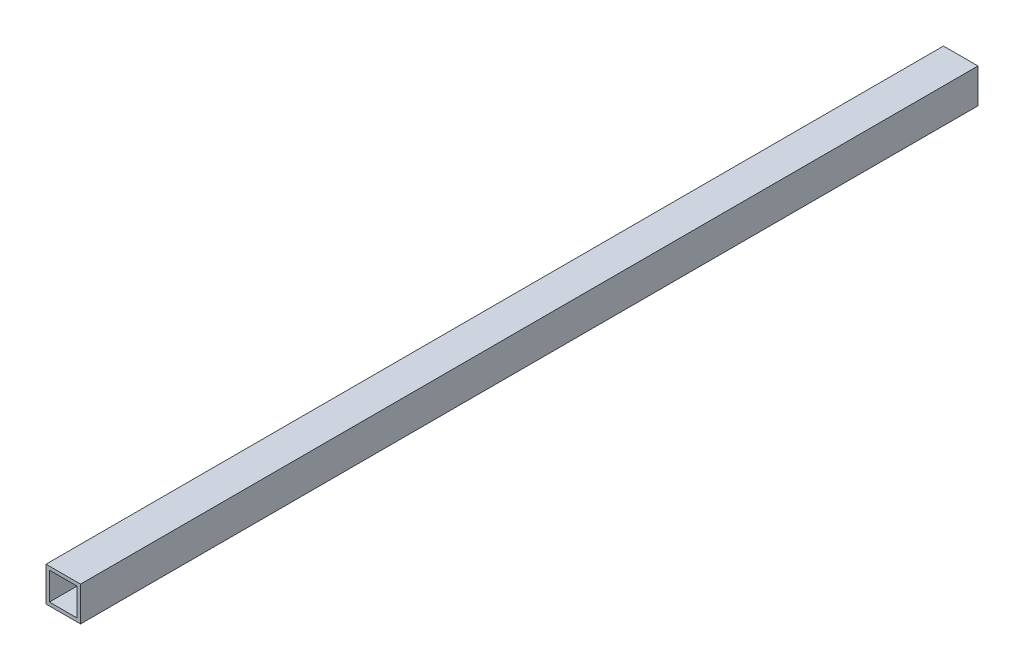
from build123d import *

# Parameters (mm, degrees)
SKETCH1_W   = 40
SKETCH1_H   = 40
SKETCH1_W_2 = 32
SKETCH1_H_2 = 32


with BuildPart() as part:
    # Sweep1: sweep along a curve in space
    with BuildLine() as sweep1_path:
        add(Edge.make_bspline(
            [(0, 0, -520), (0, 0, 520)],
            knots=[0, 0, 1, 1], degree=1))
    # Sketch1 → Sweep1 (sweep)
    with BuildSketch(Plane.XY):
        Rectangle(SKETCH1_W, SKETCH1_H)
        Rectangle(SKETCH1_W_2, SKETCH1_H_2, mode=Mode.SUBTRACT)
    sweep(path=sweep1_path.line)


solid = part.part
